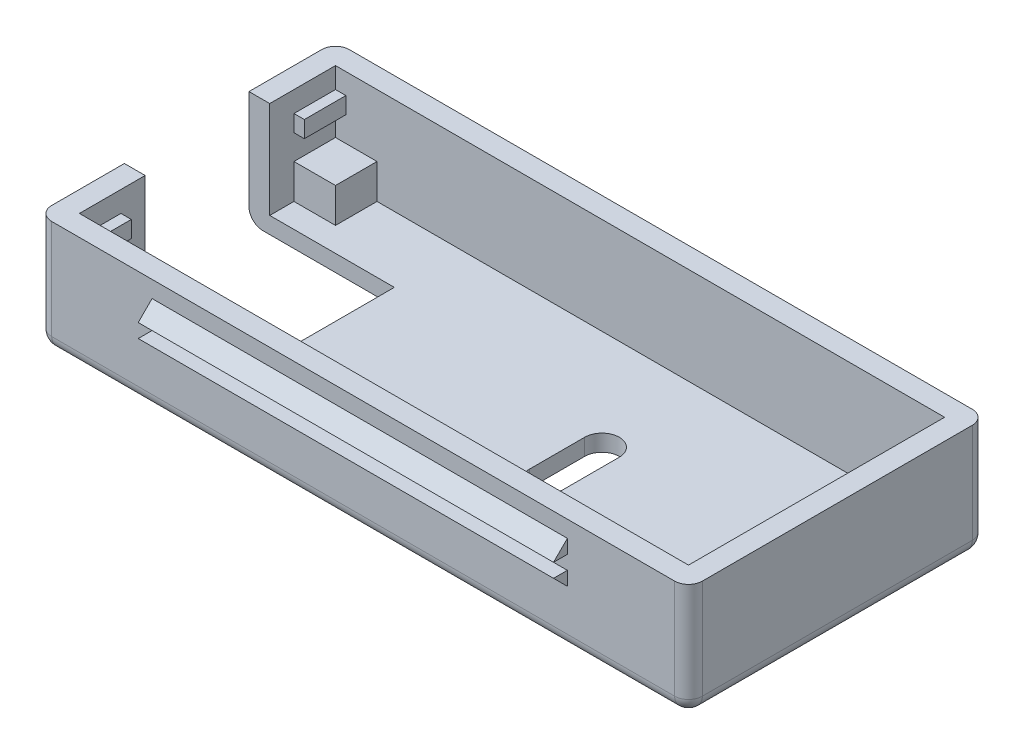
from build123d import *

# Parameters (mm, degrees)
SKETCH1_W                = 47
SKETCH1_H                = 21.5
SKETCH1_W_2              = 44
SKETCH1_H_2              = 18.5
EXTRUDE_THIN1_DEPTH      = 7
SKETCH2_W                = 47
SKETCH2_H                = 21.5
BOSS_EXTRUDE1_DEPTH      = 1.2
SKETCH3_W                = 21
SKETCH3_H                = 9
CUT_EXTRUDE1_DEPTH       = 9.2
CUT_EXTRUDE2_DEPTH       = 9.2
SKETCH5_W                = 44
SKETCH5_H                = 18.5
BOSS_EXTRUDE2_DEPTH      = 1.2
SKETCH6_W                = 44
SKETCH6_H                = 12.5
CUT_EXTRUDE3_DEPTH       = 1.2
SKETCH9_W                = 42.5
SKETCH9_H                = 18.5
CUT_EXTRUDE4_DEPTH       = 3
BOSS_EXTRUDE3_DEPTH      = 15
BOSS_EXTRUDE3_DEPTH_BACK = 15
SKETCH13_W               = 3
SKETCH13_H               = 3
BOSS_EXTRUDE4_DEPTH      = 2.5
FILLET1_R                = 1
FILLET2_R                = 1


with BuildPart() as part:
    # Sketch1 → Extrude-Thin1 (new body)
    with BuildSketch(Plane(origin=(0, 0, 0), x_dir=(1, 0, 0), z_dir=(0, 1, 0))):
        with Locations((22, 9.25)):
            Rectangle(SKETCH1_W, SKETCH1_H)
        with Locations((22, 9.25)):
            Rectangle(SKETCH1_W_2, SKETCH1_H_2, mode=Mode.SUBTRACT)
    extrude(amount=EXTRUDE_THIN1_DEPTH)

    # Sketch2 → Boss-Extrude1 (add)
    with BuildSketch(Plane.XZ):
        with Locations((22, -9.25)):
            Rectangle(SKETCH2_W, SKETCH2_H)
    extrude(amount=BOSS_EXTRUDE1_DEPTH)

    # Sketch3 → Cut-Extrude1 (cut, through all)
    with BuildSketch(Plane.XZ.offset(1.2)):
        with Locations((-1.5, -9.25)):
            Rectangle(SKETCH3_W, SKETCH3_H)
    extrude(amount=-CUT_EXTRUDE1_DEPTH, mode=Mode.SUBTRACT)

    # Sketch4 → Cut-Extrude2 (cut, through all)
    with BuildSketch(Plane.XZ.offset(1.2)):
        with BuildLine():
            Line((25.25, -11.25), (25.25, -7.25))
            ThreePointArc((25.25, -7.25), (26.5, -6), (27.75, -7.25))
            Line((27.75, -7.25), (27.75, -11.25))
            ThreePointArc((27.75, -11.25), (26.5, -12.5), (25.25, -11.25))
        make_face()
        with BuildLine():
            Line((43.75, -11.25), (43.75, -7.25))
            ThreePointArc((43.75, -7.25), (42.5, -6), (41.25, -7.25))
            Line((41.25, -7.25), (41.25, -11.25))
            ThreePointArc((41.25, -11.25), (42.5, -12.5), (43.75, -11.25))
        make_face()
    extrude(amount=-CUT_EXTRUDE2_DEPTH, mode=Mode.SUBTRACT)

    # Sketch5 → Boss-Extrude2 (add)
    with BuildSketch(Plane(origin=(0, 5.5, 0), x_dir=(-1, 0, 0), z_dir=(0, -1, 0))):
        with Locations((-22, 9.25)):
            Rectangle(SKETCH5_W, SKETCH5_H)
    extrude(amount=BOSS_EXTRUDE2_DEPTH)

    # Sketch6 → Cut-Extrude3 (cut)
    with BuildSketch(Plane(origin=(0, 4.3, 0), x_dir=(-1, 0, 0), z_dir=(0, -1, 0))):
        with Locations((-22, 9.25)):
            Rectangle(SKETCH6_W, SKETCH6_H)
    extrude(amount=-CUT_EXTRUDE3_DEPTH, mode=Mode.SUBTRACT)

    # Sketch9 → Cut-Extrude4 (cut)
    with BuildSketch(Plane(origin=(0, 5.5, 0), x_dir=(1, 0, 0), z_dir=(0, 1, 0))):
        with Locations((22, 9.25)):
            Rectangle(SKETCH9_W, SKETCH9_H)
    extrude(amount=-CUT_EXTRUDE4_DEPTH, mode=Mode.SUBTRACT)

    # Sketch10 → Boss-Extrude3 (add, two sides)
    with BuildSketch(Plane.ZY.offset(-21.75)) as boss_extrude3_sk:
        Polygon((-20, 2.8), (-21, 3.8), (-20, 3.8), align=None)
        Polygon((2.5, 3.8), (1.5, 3.8), (1.5, 2.8), align=None)
        Polygon((1.5, 5.8), (2.5, 4.8), (1.5, 4.8), align=None)
        Polygon((-21, 4.8), (-20, 4.8), (-20, 5.8), align=None)
    extrude(amount=BOSS_EXTRUDE3_DEPTH)
    extrude(boss_extrude3_sk.sketch, amount=-BOSS_EXTRUDE3_DEPTH_BACK)

    # Sketch13 → Boss-Extrude4 (add)
    with BuildSketch(Plane(origin=(0, 0, 0), x_dir=(1, 0, 0), z_dir=(0, 1, 0))):
        with Locations((1.5, 1.5)):
            Rectangle(SKETCH13_W, SKETCH13_H)
        with Locations((42.5, 17)):
            Rectangle(SKETCH13_W, SKETCH13_H)
        with Locations((42.5, 1.5)):
            Rectangle(SKETCH13_W, SKETCH13_H)
        with Locations((1.5, 17)):
            Rectangle(SKETCH13_W, SKETCH13_H)
    extrude(amount=BOSS_EXTRUDE4_DEPTH)

    # Fillet1
    fillet1_edges = [part.edges().sort_by_distance(p)[0] for p in [
        (-1.5, 2.9, -20),
        (45.5, 2.9, -20),
        (45.5, 2.9, 1.5),
        (-1.5, 2.9, 1.5),
    ]]
    fillet(fillet1_edges, radius=FILLET1_R)

    # Fillet2
    fillet2_edges = [part.edges().sort_by_distance(p)[0] for p in [
        (22, -1.2, -20),
        (45.5, -1.2, -9.25),
        (22, -1.2, 1.5),
        (-1.5, -1.2, -2.125),
        (-1.207106781, -1.2, 1.207106781),
        (45.207106781, -1.2, 1.207106781),
        (45.207106781, -1.2, -19.707106781),
        (-1.207106781, -1.2, -19.707106781),
        (-1.5, -1.2, -16.375),
    ]]
    fillet(fillet2_edges, radius=FILLET2_R)


solid = part.part
